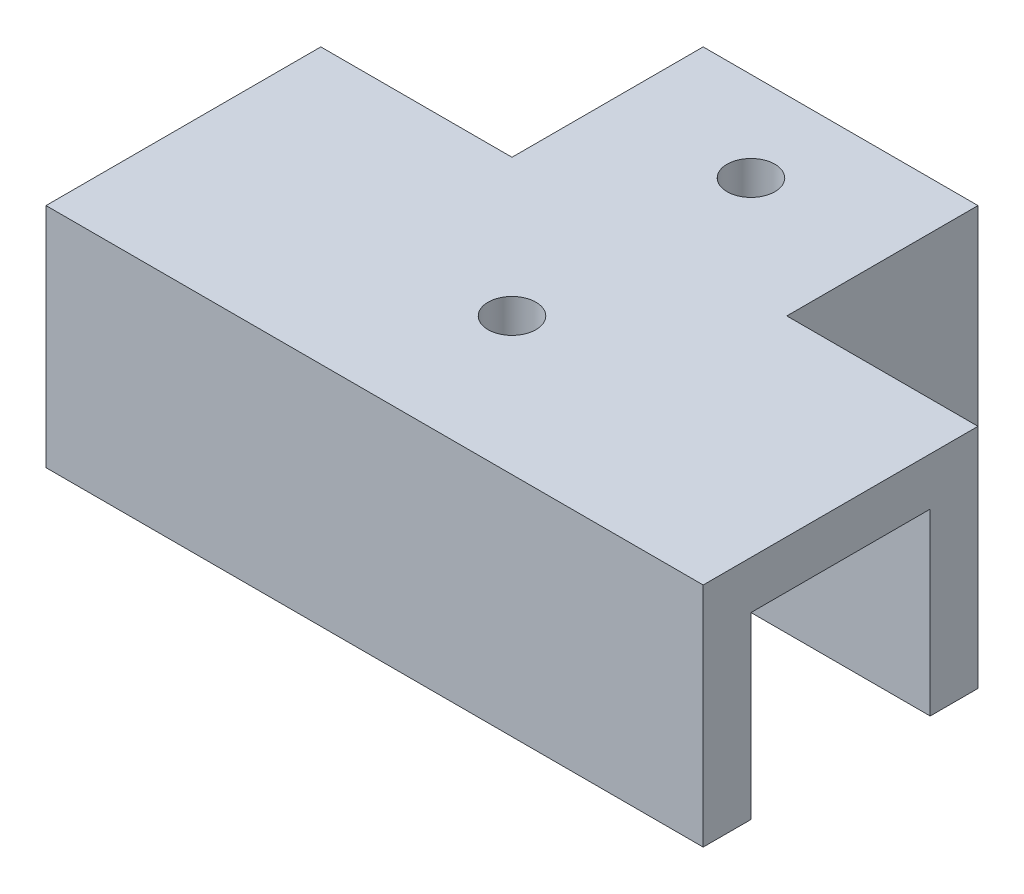
from build123d import *

# Parameters (mm, degrees)
EXTRUDE_1_DEPTH     = 15
EXTRUDE_1_2_DEPTH   = 15
SKETCH_1_W          = 55
SKETCH_1_H          = 4
EXTRUDE_1_3_DEPTH   = 15
SKETCH_2_W          = 55
SKETCH_2_H          = 23
SKETCH_2_W_2        = 23
SKETCH_2_H_2        = 16
EXTRUDE_2_DEPTH     = 4
SKETCH_3_R          = 2
CUT_EXTRUDE_1_DEPTH = 4


with BuildPart() as part:
    # 草图1 → 凸台-拉伸1 (new body)
    with BuildSketch(Plane(origin=(0, 0, 0), x_dir=(1, 0, 0), z_dir=(0, 1, 0))):
        Polygon((-13.428571429, 15.821428571), (-29.428571429, 15.821428571), (-29.428571429, 11.821428571), (-11.428571429, 11.821428571), (-9.428571429, 11.821428571), (-9.428571429, 15.821428571), (-9.428571429, 31.821428571), (-13.428571429, 31.821428571), align=None)
    extrude(amount=EXTRUDE_1_DEPTH)



with BuildPart() as body_2:
    # 草图1 → Extrude 1 2 (new body)
    with BuildSketch(Plane(origin=(0, 0, 0), x_dir=(1, 0, 0), z_dir=(0, 1, 0))):
        Polygon((9.571428571, 31.821428571), (5.571428571, 31.821428571), (5.571428571, 15.821428571), (5.571428571, 11.821428571), (14.214285714, 11.821428571), (25.571428571, 11.821428571), (25.571428571, 15.821428571), (9.571428571, 15.821428571), align=None)
    extrude(amount=EXTRUDE_1_2_DEPTH)


with BuildPart() as body_3:
    # 草图1 → Extrude 1 3 (new body)
    with BuildSketch(Plane(origin=(0, 0, 0), x_dir=(1, 0, 0), z_dir=(0, 1, 0))):
        with Locations((-1.928571429, -5.178571429)):
            Rectangle(SKETCH_1_W, SKETCH_1_H)
    extrude(amount=EXTRUDE_1_3_DEPTH)


with BuildPart() as part_1:
    add(part.part)

    add(body_2.part)  # 凸台-拉伸2 merges body 2

    add(body_3.part)  # 凸台-拉伸2 merges body 3
    # 草图2 → 凸台-拉伸2 (add)
    with BuildSketch(Plane(origin=(0, 15, 0), x_dir=(1, 0, 0), z_dir=(0, 1, 0))):
        with Locations((-1.928571429, 4.321428571)):
            Rectangle(SKETCH_2_W, SKETCH_2_H)
        with Locations((-1.928571429, 23.821428571)):
            Rectangle(SKETCH_2_W_2, SKETCH_2_H_2)
    extrude(amount=EXTRUDE_2_DEPTH)

    # 草图3 → 切除-拉伸1 (cut)
    with BuildSketch(Plane(origin=(0, 19, 0), x_dir=(1, 0, 0), z_dir=(0, 1, 0))):
        with Locations((-1.928571429, 24.321428571)):
            Circle(SKETCH_3_R)
        with Locations((-1.928571429, 4.321428571)):
            Circle(SKETCH_3_R)
    extrude(amount=-CUT_EXTRUDE_1_DEPTH, mode=Mode.SUBTRACT)


solid = part_1.part
